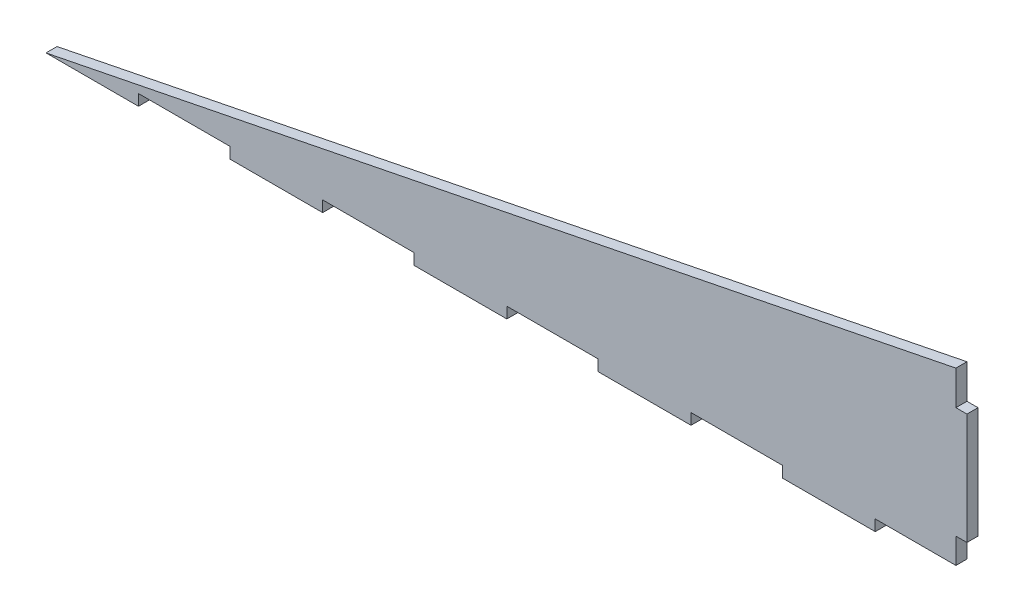
from build123d import *

# Parameters (mm, degrees)
SKETCH1_W           = 3
SKETCH1_H           = 30.2
BOSS_EXTRUDE1_DEPTH = 3


with BuildPart() as part:
    # Sketch1 → Boss-Extrude1 (new body)
    with BuildSketch(Plane.XY):
        Polygon((247, 49.4), (0, 0), (25.1, 0), (25.1, 3), (49.9, 3), (49.9, 0), (75.1, 0), (75.1, 3), (99.9, 3), (99.9, 0), (125.1, 0), (125.1, 3), (149.9, 3), (149.9, 0), (175.1, 0), (175.1, 3), (199.9, 3), (199.9, 0), (225.1, 0), (225.1, 3), (247, 3), (247, 9.9), (247, 40.1), align=None)
        with Locations((248.5, 25)):
            Rectangle(SKETCH1_W, SKETCH1_H)
    extrude(amount=BOSS_EXTRUDE1_DEPTH)


solid = part.part
